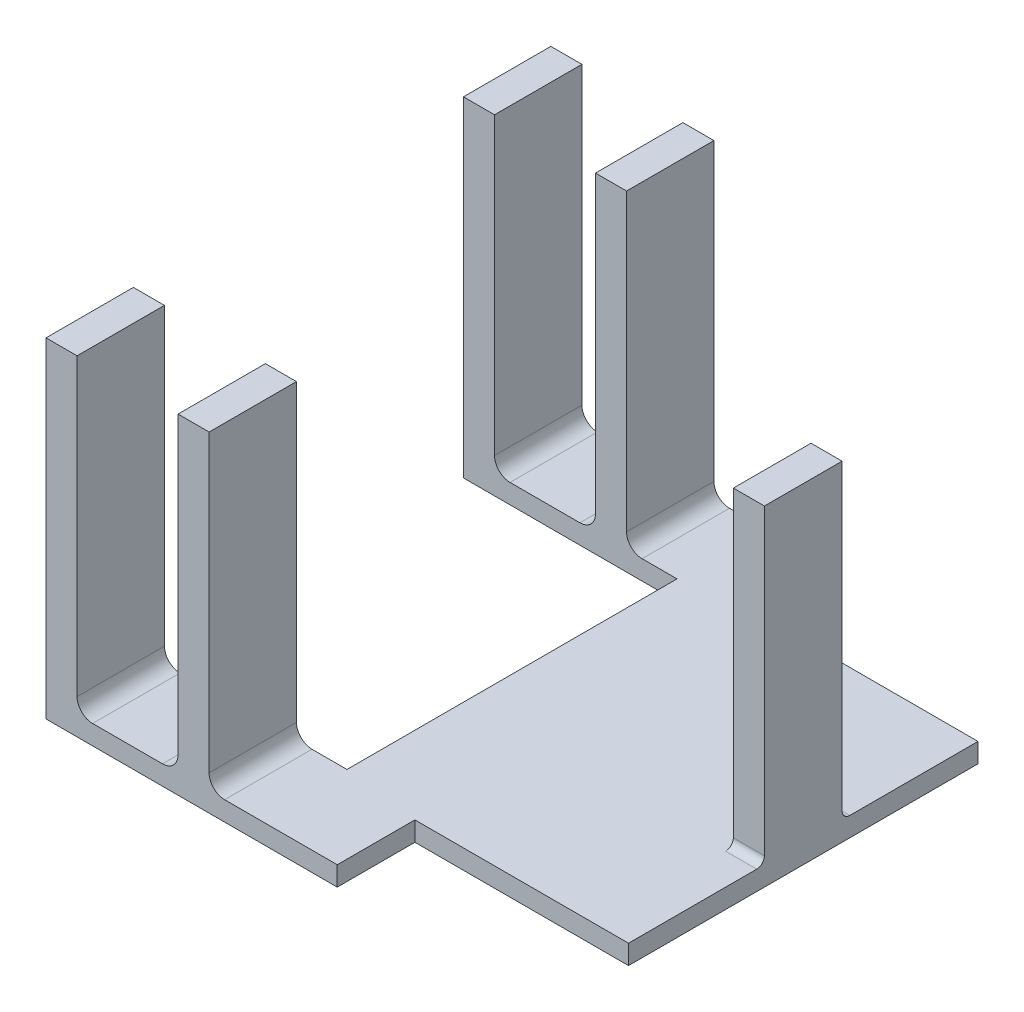
from build123d import *

# Parameters (mm, degrees)
BOSS_EXTRUDE1_DEPTH = 6.35
SKETCH4_W           = 10.16
SKETCH4_H           = 28.575
BOSS_EXTRUDE4_DEPTH = 101.6
SKETCH5_W           = 10.16
SKETCH5_H           = 28.575
BOSS_EXTRUDE5_DEPTH = 101.6
SKETCH6_W           = 10.16
SKETCH6_H           = 25.4
BOSS_EXTRUDE7_DEPTH = 101.6
FILLET2_R           = 5.08
FILLET3_R           = 5.08
FILLET4_R           = 5.08
FILLET5_R           = 5.08
FILLET6_R           = 5.08
FILLET7_R           = 5.08
FILLET8_R           = 2.54
FILLET9_R           = 2.54


with BuildPart() as part:
    # Sketch1 → Boss-Extrude1 (new body)
    with BuildSketch(Plane(origin=(0, 0, 0), x_dir=(1, 0, 0), z_dir=(0, 1, 0))):
        Polygon((0, 114.3), (0, 139.7), (-95.25, 139.7), (-95.25, 111.125), (-25.4, 111.125), (-25.4, 3.175), (-95.25, 3.175), (-95.25, -25.4), (0, -25.4), (0, 0), (69.85, 0), (69.85, 114.3), align=None)
    extrude(amount=BOSS_EXTRUDE1_DEPTH)

    # Sketch4 → Boss-Extrude4 (add)
    with BuildSketch(Plane(origin=(0, 6.35, 0), x_dir=(1, 0, 0), z_dir=(0, 1, 0))):
        with Locations((-90.17, -11.1125)):
            Rectangle(SKETCH4_W, SKETCH4_H)
        with Locations((-46.99, -11.1125)):
            Rectangle(SKETCH4_W, SKETCH4_H)
    extrude(amount=BOSS_EXTRUDE4_DEPTH)

    # Sketch5 → Boss-Extrude5 (add)
    with BuildSketch(Plane(origin=(0, 6.35, 0), x_dir=(1, 0, 0), z_dir=(0, 1, 0))):
        with Locations((-90.17, 125.4125)):
            Rectangle(SKETCH5_W, SKETCH5_H)
        with Locations((-46.99, 125.4125)):
            Rectangle(SKETCH5_W, SKETCH5_H)
    extrude(amount=BOSS_EXTRUDE5_DEPTH)

    # Sketch6 → Boss-Extrude7 (add)
    with BuildSketch(Plane(origin=(0, 6.35, 0), x_dir=(1, 0, 0), z_dir=(0, 1, 0))):
        with Locations((64.77, 57.15)):
            Rectangle(SKETCH6_W, SKETCH6_H)
    extrude(amount=BOSS_EXTRUDE7_DEPTH)

    # Fillet2
    fillet2_edges = [part.edges().sort_by_distance(p)[0] for p in [
        (-41.91, 6.35, 11.1125),
    ]]
    fillet(fillet2_edges, radius=FILLET2_R)

    # Fillet3
    fillet3_edges = [part.edges().sort_by_distance(p)[0] for p in [
        (-52.07, 6.35, 11.1125),
    ]]
    fillet(fillet3_edges, radius=FILLET3_R)

    # Fillet4
    fillet4_edges = [part.edges().sort_by_distance(p)[0] for p in [
        (-85.09, 6.35, 11.1125),
    ]]
    fillet(fillet4_edges, radius=FILLET4_R)

    # Fillet5
    fillet5_edges = [part.edges().sort_by_distance(p)[0] for p in [
        (-85.09, 6.35, -125.4125),
    ]]
    fillet(fillet5_edges, radius=FILLET5_R)

    # Fillet6
    fillet6_edges = [part.edges().sort_by_distance(p)[0] for p in [
        (-52.07, 6.35, -125.4125),
    ]]
    fillet(fillet6_edges, radius=FILLET6_R)

    # Fillet7
    fillet7_edges = [part.edges().sort_by_distance(p)[0] for p in [
        (-41.91, 6.35, -125.4125),
    ]]
    fillet(fillet7_edges, radius=FILLET7_R)

    # Fillet8
    fillet8_edges = [part.edges().sort_by_distance(p)[0] for p in [
        (64.77, 6.35, -44.45),
    ]]
    fillet(fillet8_edges, radius=FILLET8_R)

    # Fillet9
    fillet9_edges = [part.edges().sort_by_distance(p)[0] for p in [
        (64.77, 6.35, -69.85),
    ]]
    fillet(fillet9_edges, radius=FILLET9_R)


solid = part.part
